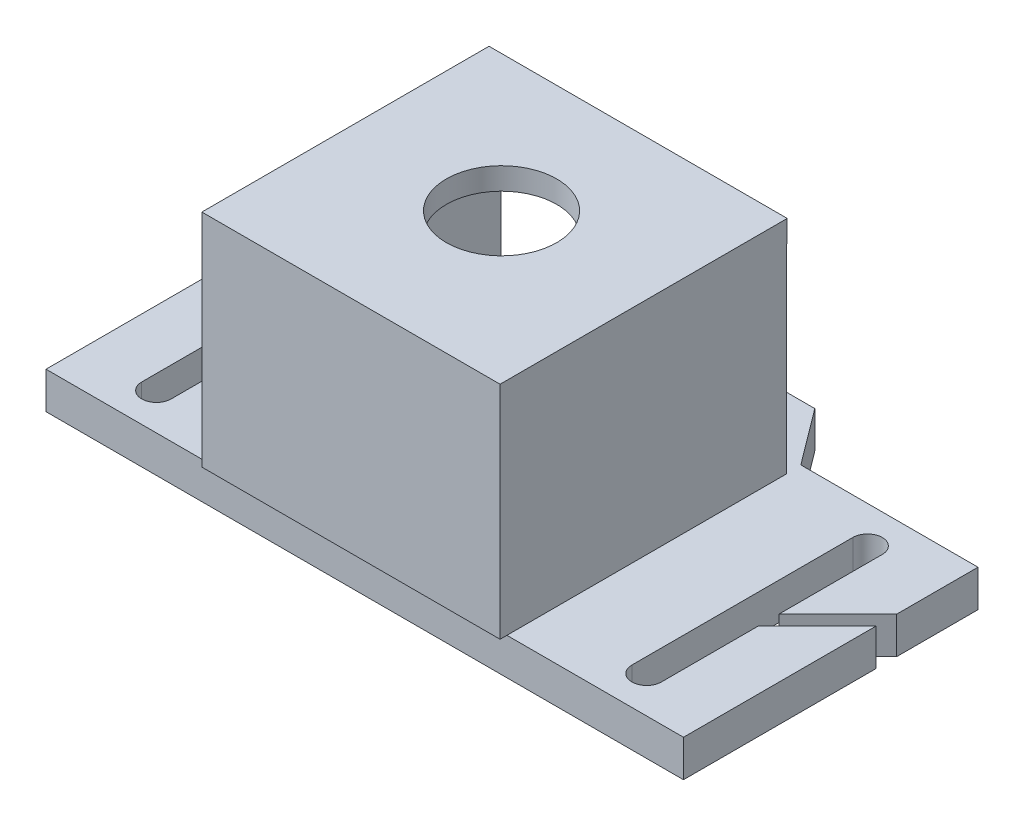
from build123d import *

# Parameters (mm, degrees)
EXTRUDE_1_DEPTH     = 5
SKETCH_4_W          = 1.8
SKETCH_4_H          = 37
EXTRUDE_2_DEPTH     = 27
SKETCH_5_W          = 40.5
SKETCH_5_H          = 37
EXTRUDE_3_DEPTH     = 3
CUT_EXTRUDE_4_DEPTH = 10
CUT_EXTRUDE_7_DEPTH = 10
CUT_EXTRUDE_8_DEPTH = 10
SKETCH_13_R         = 7.5
CUT_EXTRUDE_9_DEPTH = 10
SKETCH_14_W         = 40.5
SKETCH_14_H         = 30
EXTRUDE_4_DEPTH     = 2


with BuildPart() as part:
    # 草图1 → 凸台-拉伸1 (new body)
    with BuildSketch(Plane(origin=(0, 0, 0), x_dir=(1, 0, 0), z_dir=(0, 1, 0))):
        Polygon((13.545654436, 26.428234879), (-13.545654436, 26.428234879), (-19.229145808, 18.850246383), (-43.289259281, 18.850246383), (-43.289259281, -21.149753617), (43.289259281, -21.149753617), (43.289259281, 18.850246383), (19.229145808, 18.850246383), align=None)
    extrude(amount=EXTRUDE_1_DEPTH)

    # 草图4 → 凸台-拉伸2 (add)
    with BuildSketch(Plane(origin=(0, 5, 0), x_dir=(1, 0, 0), z_dir=(0, 1, 0))):
        with Locations((-20.389259281, -1.649753617)):
            Rectangle(SKETCH_4_W, SKETCH_4_H)
        with Locations((18.410740719, -1.649753617)):
            Rectangle(SKETCH_4_W, SKETCH_4_H)
    extrude(amount=EXTRUDE_2_DEPTH)

    # 草图5 → 凸台-拉伸3 (add)
    with BuildSketch(Plane(origin=(0, 32, 0), x_dir=(1, 0, 0), z_dir=(0, 1, 0))):
        with Locations((-0.939259281, -1.580342136)):
            Rectangle(SKETCH_5_W, SKETCH_5_H)
    extrude(amount=EXTRUDE_3_DEPTH)

    # 草图8 → 切除-拉伸4 (cut)
    with BuildSketch(Plane(origin=(0, 5, 0), x_dir=(1, 0, 0), z_dir=(0, 1, 0))):
        with BuildLine():
            Line((-31.289259281, 13.850246383), (-31.289259281, -16.149753617))
            ThreePointArc((-31.289259281, -16.149753617), (-33.289259281, -18.149753617), (-35.289259281, -16.149753617))
            Line((-35.289259281, -16.149753617), (-35.289259281, 13.850246383))
            ThreePointArc((-35.289259281, 13.850246383), (-33.289259281, 15.850246383), (-31.289259281, 13.850246383))
        make_face()
    extrude(amount=-CUT_EXTRUDE_4_DEPTH, mode=Mode.SUBTRACT)

    # 草图10 → 切除-拉伸7 (cut)
    with BuildSketch(Plane(origin=(0, 5, 0), x_dir=(1, 0, 0), z_dir=(0, 1, 0))):
        with BuildLine():
            Line((35.289259281, 13.850246383), (35.289259281, -16.149753617))
            ThreePointArc((35.289259281, -16.149753617), (33.289259281, -18.149753617), (31.289259281, -16.149753617))
            Line((31.289259281, -16.149753617), (31.289259281, 13.850246383))
            ThreePointArc((31.289259281, 13.850246383), (33.289259281, 15.850246383), (35.289259281, 13.850246383))
        make_face()
    extrude(amount=-CUT_EXTRUDE_7_DEPTH, mode=Mode.SUBTRACT)

    # 草图12 → 切除-拉伸8 (cut)
    with BuildSketch(Plane(origin=(0, 5, 0), x_dir=(1, 0, 0), z_dir=(0, 1, 0))):
        with BuildLine():
            Line((44.805959338, 6.484665103), (34.19935762, -4.121936615))
            ThreePointArc((34.19935762, -4.121936615), (32.785144058, -4.121936615), (32.785144058, -2.707723053))
            Line((32.785144058, -2.707723053), (43.391745776, 7.898878665))
            ThreePointArc((43.391745776, 7.898878665), (44.805959338, 7.898878665), (44.805959338, 6.484665103))
        make_face()
        with BuildLine():
            Line((-44.526375344, 6.888037873), (-33.523218079, -3.306594549))
            ThreePointArc((-33.523218079, -3.306594549), (-33.469316423, -4.719780528), (-34.882502402, -4.773682184))
            Line((-34.882502402, -4.773682184), (-45.885659667, 5.420950238))
            ThreePointArc((-45.885659667, 5.420950238), (-45.939561323, 6.834136217), (-44.526375344, 6.888037873))
        make_face()
    extrude(amount=-CUT_EXTRUDE_8_DEPTH, mode=Mode.SUBTRACT)

    # 草图13 → 切除-拉伸9 (cut)
    with BuildSketch(Plane(origin=(0, 35, 0), x_dir=(1, 0, 0), z_dir=(0, 1, 0))):
        with Locations((-0.989259281, -1.580342136)):
            Circle(SKETCH_13_R)
    extrude(amount=-CUT_EXTRUDE_9_DEPTH, mode=Mode.SUBTRACT)

    # 草图14 → 凸台-拉伸4 (add)
    with BuildSketch(Plane.XY.offset(20.080342136)):
        with Locations((-0.939259281, 20)):
            Rectangle(SKETCH_14_W, SKETCH_14_H)
    extrude(amount=EXTRUDE_4_DEPTH)


solid = part.part
